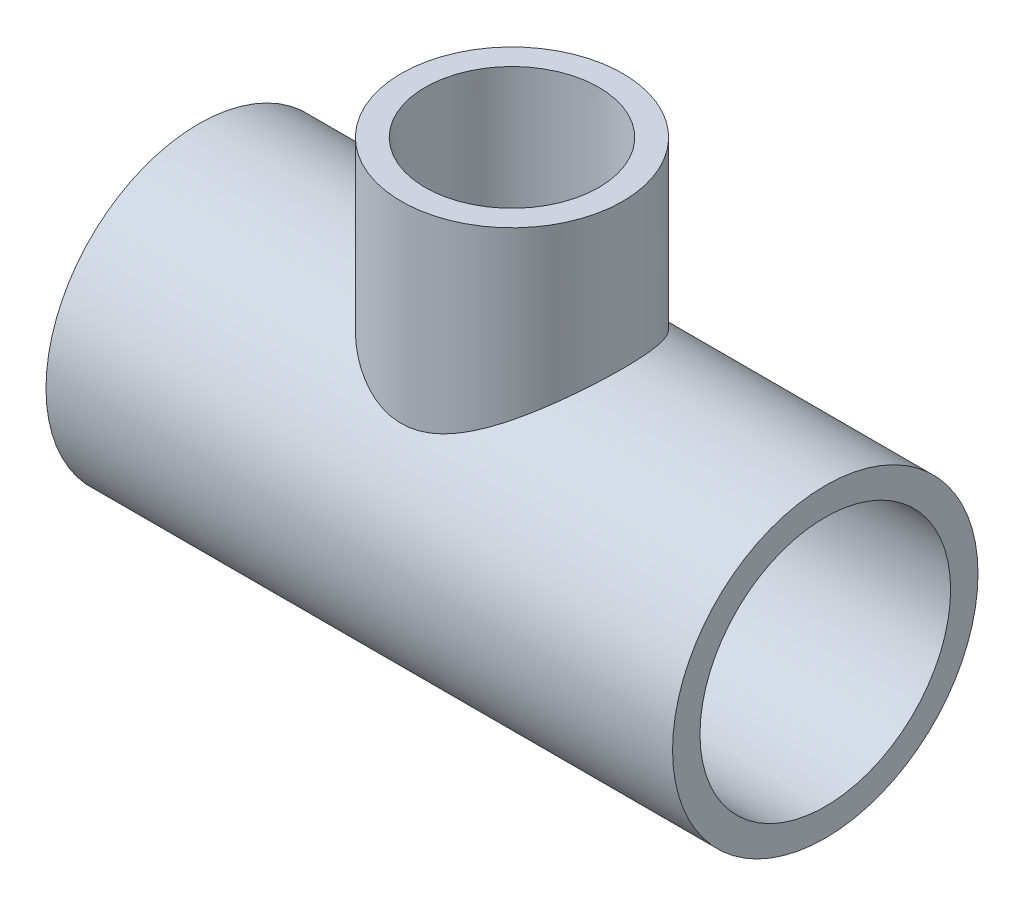
from build123d import *

# Parameters (mm, degrees)
SKETCH4_R           = 29.591
BOSS_EXTRUDE1_DEPTH = 51.308
SKETCH5_R           = 21.463
BOSS_EXTRUDE2_DEPTH = 25.908


with BuildPart() as part:
    # Sketch1 → Revolve1 (revolve)
    with BuildSketch(Plane.XY, mode=Mode.PRIVATE) as revolve1_sk:
        Polygon((-60.706, -29.591), (-25.654, -29.591), (-25.654, -24.0538), (-60.706, -24.2824), align=None)
        Polygon((60.706, -24.2824), (25.654, -24.0538), (25.654, -29.591), (60.706, -29.591), align=None)
    revolve(revolve1_sk.sketch.rotate(Axis((-60.706, 0, 0), (1, 0, 0)), 270), axis=Axis((-60.706, 0, 0), (1, 0, 0)))



with BuildPart() as body_2:
    # Sketch2 → Revolve2 (revolve)
    with BuildSketch(Plane.XY):
        Polygon((16.8275, 57.658), (16.637, 25.908), (21.463, 25.908), (21.463, 57.658), align=None)
    revolve(axis=Axis((0, 0, 0), (0, 1, 0)))


with BuildPart() as part_1:
    add(part.part)

    add(body_2.part)  # Boss-Extrude1 merges body 2
    # Sketch4 → Boss-Extrude1 (add)
    with BuildSketch(Plane(origin=(-25.654, 0, 0), x_dir=(0, 0, -1), z_dir=(1, 0, 0))):
        with Locations(Location((0, 0, 0), (0, 0, 180))):
            Circle(SKETCH4_R)
    extrude(amount=BOSS_EXTRUDE1_DEPTH)

    # Sketch5 → Boss-Extrude2 (add)
    with BuildSketch(Plane.XZ.offset(-25.908)):
        Circle(SKETCH5_R)
    extrude(amount=BOSS_EXTRUDE2_DEPTH)

    # Sketch6 → Cut-Revolve1 (revolve, cut)
    with BuildSketch(Plane.XY, mode=Mode.PRIVATE) as cut_revolve1_sk:
        Polygon((-60.706, -24.2824), (-25.654, -24.0538), (-25.654, -19.05), (25.654, -19.05), (25.654, -24.0538), (60.706, -24.2824), (60.706, 0), (-60.706, 0), align=None)
    revolve(cut_revolve1_sk.sketch.rotate(Axis((60.706, 0, 0), (-1, 0, 0)), 270), axis=Axis((60.706, 0, 0), (-1, 0, 0)), mode=Mode.SUBTRACT)

    # Sketch7 → Cut-Revolve2 (revolve, cut)
    with BuildSketch(Plane.XY):
        Polygon((16.8275, 57.658), (16.637, 25.908), (12.1539, 25.908), (12.1539, 0), (0, 0), (0, 57.658), align=None)
    revolve(axis=Axis((0, 0, 0), (0, 1, 0)), mode=Mode.SUBTRACT)


solid = part_1.part
